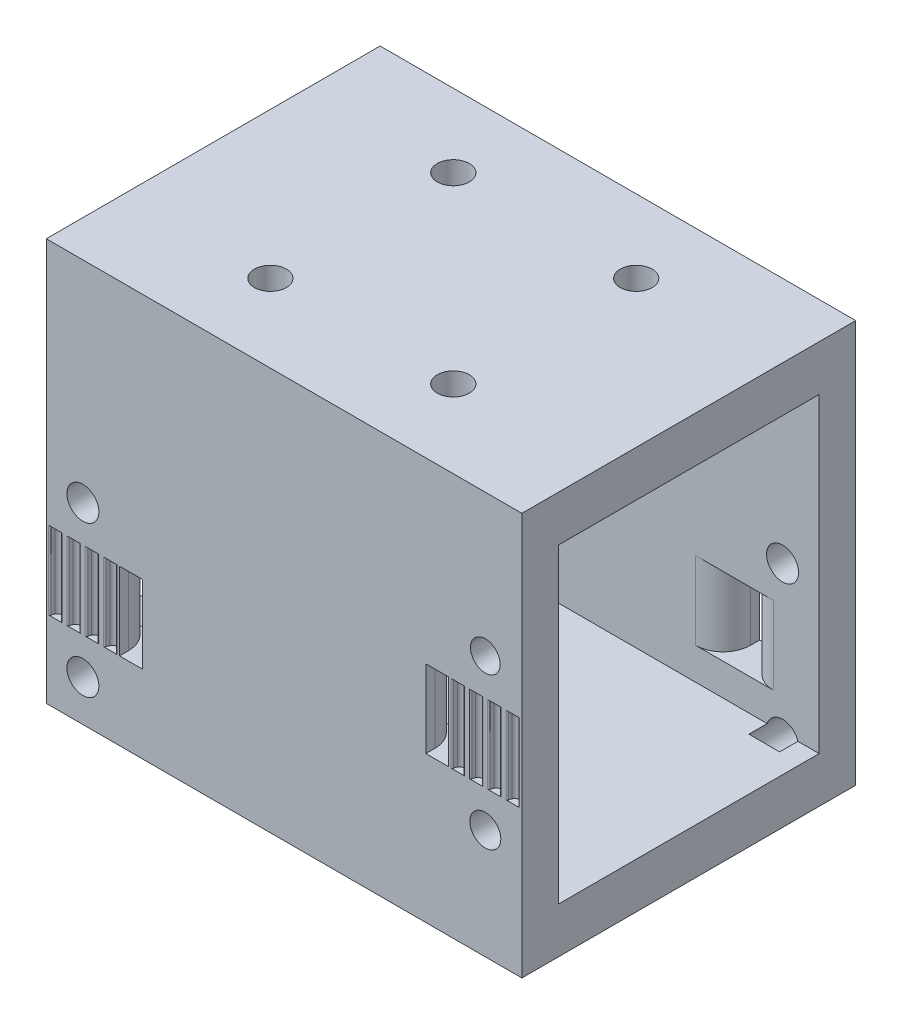
from build123d import *

# Parameters (mm, degrees)
SKETCH1_W           = 52
SKETCH1_H           = 36.5
SKETCH1_R           = 1.75
BOSS_EXTRUDE1_DEPTH = 5
SKETCH2_W           = 52
SKETCH2_H           = 4
BOSS_EXTRUDE2_DEPTH = 34
SKETCH3_W           = 52
SKETCH3_H           = 36.5
BOSS_EXTRUDE3_DEPTH = 5
SKETCH4_W           = 2.5
SKETCH4_H           = 8.5
CUT_EXTRUDE1_DEPTH  = 8
CUT_EXTRUDE2_DEPTH  = 8.5
CUT_EXTRUDE3_DEPTH  = 8.5
SKETCH7_R           = 1.75
SKETCH7_R_2         = 1.623529306
SKETCH7_R_3         = 1.694530851
CUT_EXTRUDE4_DEPTH  = 6
SKETCH8_W           = 2.5
SKETCH8_H           = 8.5
CUT_EXTRUDE5_DEPTH  = 6
FILLET1_R           = 3
SKETCH9_R           = 1.75
CUT_EXTRUDE6_DEPTH  = 6


with BuildPart() as part:
    # Sketch1 → Boss-Extrude1 (new body)
    with BuildSketch(Plane(origin=(0, 0, 0), x_dir=(1, 0, 0), z_dir=(0, 1, 0))):
        with Locations((8.063492063, 1.794973545)):
            Rectangle(SKETCH1_W, SKETCH1_H)
        with Locations((-1.936507937, 12.044973545)):
            Circle(SKETCH1_R, mode=Mode.SUBTRACT)
        with Locations((18.063492063, 12.044973545)):
            Circle(SKETCH1_R, mode=Mode.SUBTRACT)
        with Locations((18.063492063, -7.955026455)):
            Circle(SKETCH1_R, mode=Mode.SUBTRACT)
        with Locations((-1.936507937, -7.955026455)):
            Circle(SKETCH1_R, mode=Mode.SUBTRACT)
    extrude(amount=BOSS_EXTRUDE1_DEPTH)

    # Sketch2 → Boss-Extrude2 (add)
    with BuildSketch(Plane.XZ):
        with Locations((8.063492063, 14.455026455)):
            Rectangle(SKETCH2_W, SKETCH2_H)
        with Locations((8.063492063, -18.044973545)):
            Rectangle(SKETCH2_W, SKETCH2_H)
    extrude(amount=BOSS_EXTRUDE2_DEPTH)

    # Sketch3 → Boss-Extrude3 (add)
    with BuildSketch(Plane.XZ.offset(34)):
        with Locations((8.063492063, -1.794973545)):
            Rectangle(SKETCH3_W, SKETCH3_H)
    extrude(amount=BOSS_EXTRUDE3_DEPTH)

    # Sketch4 → Cut-Extrude1 (cut)
    with BuildSketch(Plane.XY.offset(16.455026455)):
        with Locations((24.813492063, -18.75)):
            Rectangle(SKETCH4_W, SKETCH4_H)
        with Locations((-8.686507937, -26.25)):
            Rectangle(SKETCH4_W, SKETCH4_H)
    extrude(amount=-CUT_EXTRUDE1_DEPTH, mode=Mode.SUBTRACT)

    # Sketch5 → Cut-Extrude2 (cut)
    with BuildSketch(Plane(origin=(0, -30.5, 0), x_dir=(1, 0, 0), z_dir=(0, 1, 0))):
        with BuildLine():
            ThreePointArc((-11.435384341, -16.016824208), (-10.936507937, -15.705026455), (-10.437631532, -16.016824208))
            ThreePointArc((-10.437631532, -16.016824208), (-10.378896222, -16.166964301), (-10.345051045, -16.324591672))
            ThreePointArc((-10.345051045, -16.324591672), (-10.295239582, -16.417797867), (-10.196332511, -16.455026455))
            Line((-10.196332511, -16.455026455), (-9.936507937, -16.455026455))
            Line((-9.936507937, -16.455026455), (-9.936507937, -17.085026455))
            Line((-9.936507937, -17.085026455), (-13.936507937, -17.085026455))
            Line((-13.936507937, -17.085026455), (-13.936507937, -16.455026455))
            Line((-13.936507937, -16.455026455), (-13.676683362, -16.455026455))
            ThreePointArc((-13.676683362, -16.455026455), (-13.577776291, -16.417797867), (-13.527964828, -16.324591672))
            ThreePointArc((-13.527964828, -16.324591672), (-13.494119651, -16.166964301), (-13.435384341, -16.016824208))
            ThreePointArc((-13.435384341, -16.016824208), (-12.936507937, -15.705026455), (-12.437631532, -16.016824208))
            ThreePointArc((-12.437631532, -16.016824208), (-12.378896222, -16.166964301), (-12.345051045, -16.324591672))
            ThreePointArc((-12.345051045, -16.324591672), (-12.295239582, -16.417797867), (-12.196332511, -16.455026455))
            Line((-12.196332511, -16.455026455), (-11.676683362, -16.455026455))
            ThreePointArc((-11.676683362, -16.455026455), (-11.577776291, -16.417797867), (-11.527964828, -16.324591672))
            ThreePointArc((-11.527964828, -16.324591672), (-11.494119651, -16.166964301), (-11.435384341, -16.016824208))
        make_face()
        with BuildLine():
            ThreePointArc((-15.435384341, -16.016824208), (-14.936507937, -15.705026455), (-14.437631532, -16.016824208))
            ThreePointArc((-14.437631532, -16.016824208), (-14.378896222, -16.166964301), (-14.345051045, -16.324591672))
            ThreePointArc((-14.345051045, -16.324591672), (-14.295239582, -16.417797867), (-14.196332511, -16.455026455))
            Line((-14.196332511, -16.455026455), (-13.936507937, -16.455026455))
            Line((-13.936507937, -16.455026455), (-13.936507937, -17.085026455))
            Line((-13.936507937, -17.085026455), (-17.936507937, -17.085026455))
            Line((-17.936507937, -17.085026455), (-17.936507937, -16.455026455))
            Line((-17.936507937, -16.455026455), (-17.676683362, -16.455026455))
            ThreePointArc((-17.676683362, -16.455026455), (-17.577776291, -16.417797867), (-17.527964828, -16.324591672))
            ThreePointArc((-17.527964828, -16.324591672), (-17.494119651, -16.166964301), (-17.435384341, -16.016824208))
            ThreePointArc((-17.435384341, -16.016824208), (-16.936507937, -15.705026455), (-16.437631532, -16.016824208))
            ThreePointArc((-16.437631532, -16.016824208), (-16.378896222, -16.166964301), (-16.345051045, -16.324591672))
            ThreePointArc((-16.345051045, -16.324591672), (-16.295239582, -16.417797867), (-16.196332511, -16.455026455))
            Line((-16.196332511, -16.455026455), (-15.676683362, -16.455026455))
            ThreePointArc((-15.676683362, -16.455026455), (-15.577776291, -16.417797867), (-15.527964828, -16.324591672))
            ThreePointArc((-15.527964828, -16.324591672), (-15.494119651, -16.166964301), (-15.435384341, -16.016824208))
        make_face()
    extrude(amount=CUT_EXTRUDE2_DEPTH, mode=Mode.SUBTRACT)

    # Sketch6 → Cut-Extrude3 (cut)
    with BuildSketch(Plane(origin=(0, -23, 0), x_dir=(1, 0, 0), z_dir=(0, 1, 0))):
        with BuildLine():
            ThreePointArc((28.564615659, -16.016824208), (29.063492063, -15.705026455), (29.562368468, -16.016824208))
            ThreePointArc((29.562368468, -16.016824208), (29.621103778, -16.166964301), (29.654948955, -16.324591672))
            ThreePointArc((29.654948955, -16.324591672), (29.704760418, -16.417797867), (29.803667489, -16.455026455))
            Line((29.803667489, -16.455026455), (30.063492063, -16.455026455))
            Line((30.063492063, -16.455026455), (30.063492063, -17.085026455))
            Line((30.063492063, -17.085026455), (26.063492063, -17.085026455))
            Line((26.063492063, -17.085026455), (26.063492063, -16.455026455))
            Line((26.063492063, -16.455026455), (26.323316638, -16.455026455))
            ThreePointArc((26.323316638, -16.455026455), (26.422223709, -16.417797867), (26.472035172, -16.324591672))
            ThreePointArc((26.472035172, -16.324591672), (26.505880349, -16.166964301), (26.564615659, -16.016824208))
            ThreePointArc((26.564615659, -16.016824208), (27.063492063, -15.705026455), (27.562368468, -16.016824208))
            ThreePointArc((27.562368468, -16.016824208), (27.621103778, -16.166964301), (27.654948955, -16.324591672))
            ThreePointArc((27.654948955, -16.324591672), (27.704760418, -16.417797867), (27.803667489, -16.455026455))
            Line((27.803667489, -16.455026455), (28.323316638, -16.455026455))
            ThreePointArc((28.323316638, -16.455026455), (28.422223709, -16.417797867), (28.472035172, -16.324591672))
            ThreePointArc((28.472035172, -16.324591672), (28.505880349, -16.166964301), (28.564615659, -16.016824208))
        make_face()
        with BuildLine():
            ThreePointArc((32.564615659, -16.016824208), (33.063492063, -15.705026455), (33.562368468, -16.016824208))
            ThreePointArc((33.562368468, -16.016824208), (33.621103778, -16.166964301), (33.654948955, -16.324591672))
            ThreePointArc((33.654948955, -16.324591672), (33.704760418, -16.417797867), (33.803667489, -16.455026455))
            Line((33.803667489, -16.455026455), (34.063492063, -16.455026455))
            Line((34.063492063, -16.455026455), (34.063492063, -17.085026455))
            Line((34.063492063, -17.085026455), (30.063492063, -17.085026455))
            Line((30.063492063, -17.085026455), (30.063492063, -16.455026455))
            Line((30.063492063, -16.455026455), (30.323316638, -16.455026455))
            ThreePointArc((30.323316638, -16.455026455), (30.422223709, -16.417797867), (30.472035172, -16.324591672))
            ThreePointArc((30.472035172, -16.324591672), (30.505880349, -16.166964301), (30.564615659, -16.016824208))
            ThreePointArc((30.564615659, -16.016824208), (31.063492063, -15.705026455), (31.562368468, -16.016824208))
            ThreePointArc((31.562368468, -16.016824208), (31.621103778, -16.166964301), (31.654948955, -16.324591672))
            ThreePointArc((31.654948955, -16.324591672), (31.704760418, -16.417797867), (31.803667489, -16.455026455))
            Line((31.803667489, -16.455026455), (32.323316638, -16.455026455))
            ThreePointArc((32.323316638, -16.455026455), (32.422223709, -16.417797867), (32.472035172, -16.324591672))
            ThreePointArc((32.472035172, -16.324591672), (32.505880349, -16.166964301), (32.564615659, -16.016824208))
        make_face()
    extrude(amount=CUT_EXTRUDE3_DEPTH, mode=Mode.SUBTRACT)

    # Sketch7 → Cut-Extrude4 (cut)
    with BuildSketch(Plane.XY.offset(16.455026455)):
        with Locations((-13.936507937, -34.5)):
            Circle(SKETCH7_R)
        with Locations((-13.936507937, -18)):
            Circle(SKETCH7_R)
        with Locations((30.063492063, -10.5)):
            Circle(SKETCH7_R_2)
        with Locations((30.063492063, -27)):
            Circle(SKETCH7_R_3)
    extrude(amount=-CUT_EXTRUDE4_DEPTH, mode=Mode.SUBTRACT)

    # Sketch8 → Cut-Extrude5 (cut)
    with BuildSketch(Plane(origin=(0, 0, -20.044973545), x_dir=(-1, 0, 0), z_dir=(0, 0, -1))):
        with Locations((-24.813492063, -26.25)):
            Rectangle(SKETCH8_W, SKETCH8_H)
        with Locations((8.686507937, -18.75)):
            Rectangle(SKETCH8_W, SKETCH8_H)
    extrude(amount=-CUT_EXTRUDE5_DEPTH, mode=Mode.SUBTRACT)

    # Fillet1
    fillet1_edges = [part.edges().sort_by_distance(p)[0] for p in [
        (-9.936507937, -18.75, -16.044973545),
        (-7.436507937, -18.75, -16.044973545),
        (23.563492063, -26.25, -16.044973545),
        (26.063492063, -26.25, -16.044973545),
        (-7.436507937, -26.25, 12.455026455),
        (-9.936507937, -26.25, 12.455026455),
        (23.563492063, -18.75, 12.455026455),
        (26.063492063, -18.75, 12.455026455),
    ]]
    fillet(fillet1_edges, radius=FILLET1_R)

    # Sketch9 → Cut-Extrude6 (cut)
    with BuildSketch(Plane(origin=(0, 0, -20.044973545), x_dir=(-1, 0, 0), z_dir=(0, 0, -1))):
        with Locations((13.936507937, -10.5)):
            Circle(SKETCH9_R)
        with Locations((13.936507937, -27)):
            Circle(SKETCH9_R)
        with Locations((-30.063492063, -18)):
            Circle(SKETCH9_R)
        with Locations((-30.063492063, -34.5)):
            Circle(SKETCH9_R)
    extrude(amount=-CUT_EXTRUDE6_DEPTH, mode=Mode.SUBTRACT)


solid = part.part
